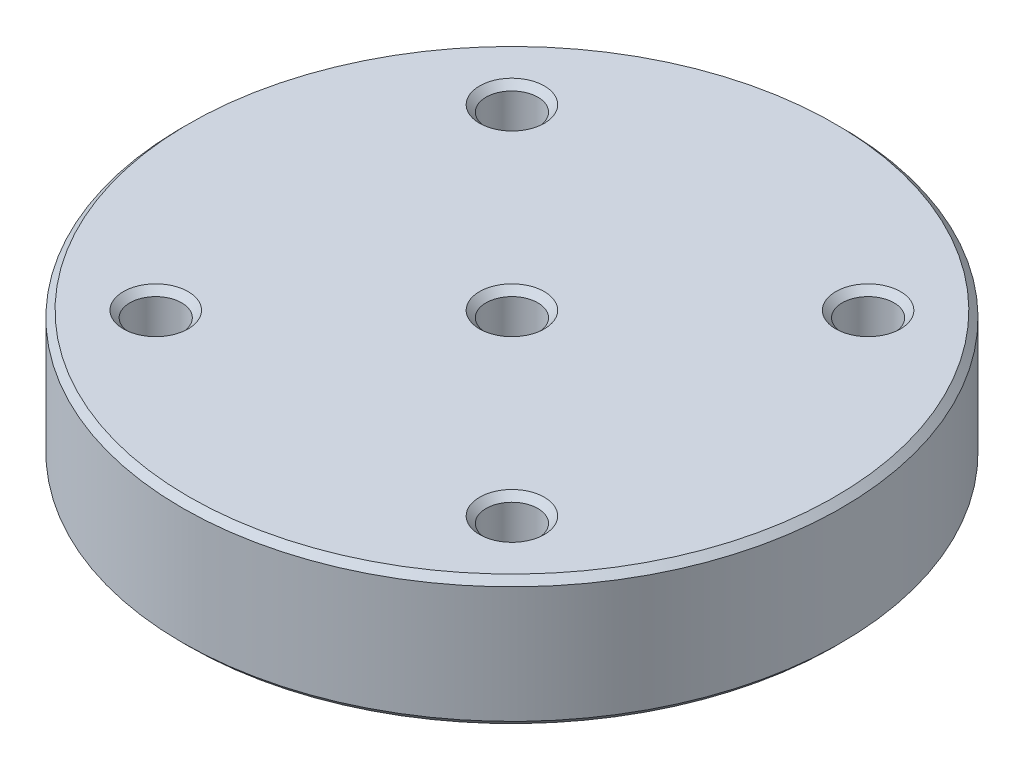
from build123d import *

# Parameters (mm, degrees)
SKETCH1_R           = 20.356349186
SKETCH1_R_2         = 1.6
BOSS_EXTRUDE1_DEPTH = 8
CHAMFER1_SIZE       = 0.4


with BuildPart() as part:
    # Sketch1 → Boss-Extrude1 (new body)
    with BuildSketch(Plane(origin=(0, 0, 0), x_dir=(1, 0, 0), z_dir=(0, 1, 0))):
        Circle(SKETCH1_R)
        Circle(SKETCH1_R_2, mode=Mode.SUBTRACT)
        with Locations((-11, 11)):
            Circle(SKETCH1_R_2, mode=Mode.SUBTRACT)
        with Locations((11, 11)):
            Circle(SKETCH1_R_2, mode=Mode.SUBTRACT)
        with Locations((11, -11)):
            Circle(SKETCH1_R_2, mode=Mode.SUBTRACT)
        with Locations((-11, -11)):
            Circle(SKETCH1_R_2, mode=Mode.SUBTRACT)
    extrude(amount=BOSS_EXTRUDE1_DEPTH)

    # Chamfer1
    chamfer1_edges = [part.edges().sort_by_distance(p)[0] for p in [
        (9.4, 0, -11),
        (9.4, 8, -11),
        (9.4, 0, 11),
        (9.4, 8, 11),
        (-20.356349186, 0, 0),
        (-12.6, 0, 11),
        (-12.6, 8, 11),
        (-20.356349186, 8, 0),
        (-1.6, 0, 0),
        (-1.6, 8, 0),
        (-12.6, 0, -11),
        (-12.6, 8, -11),
    ]]
    chamfer(chamfer1_edges, length=CHAMFER1_SIZE)


solid = part.part
